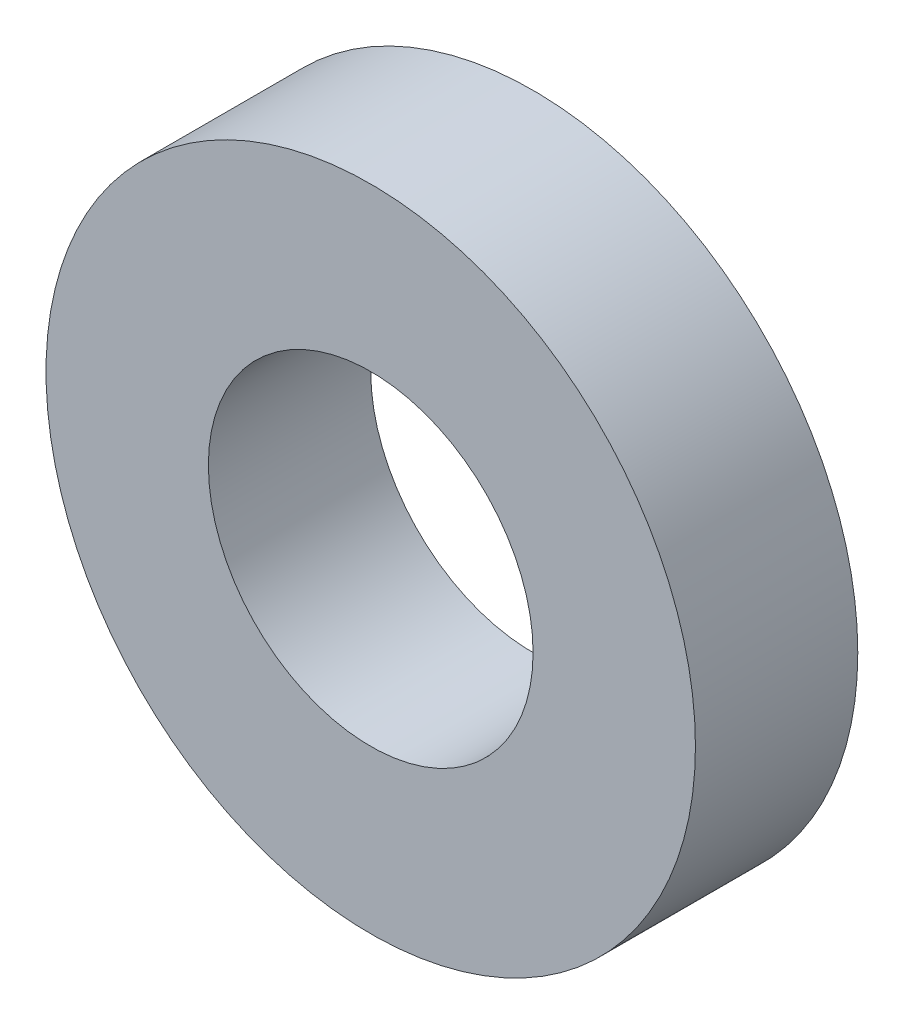
from build123d import *

# Parameters (mm, degrees)
SKETCH2_R           = 8
SKETCH2_R_2         = 4
BOSS_EXTRUDE1_DEPTH = 2


with BuildPart() as part:
    # Sketch2 → Boss-Extrude1 (new, symmetric)
    with BuildSketch(Plane.XY):
        Circle(SKETCH2_R)
        Circle(SKETCH2_R_2, mode=Mode.SUBTRACT)
    extrude(amount=BOSS_EXTRUDE1_DEPTH, both=True)


solid = part.part
